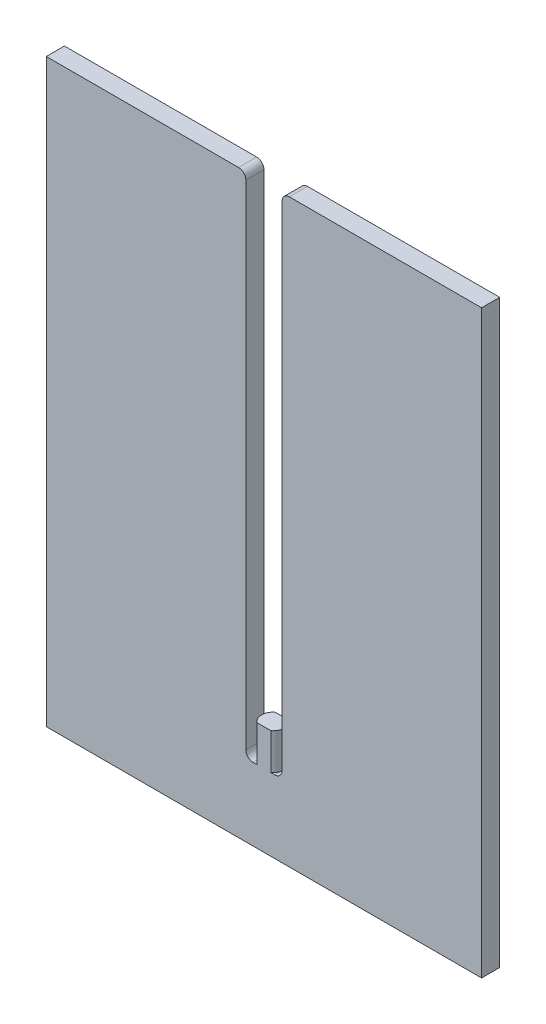
from build123d import *

# Parameters (mm, degrees)
BOSS_EXTRUDE1_DEPTH = 2.5
FILLET1_R           = 1
BOSS_EXTRUDE2_DEPTH = 5


with BuildPart() as part:
    # Sketch1 → Boss-Extrude1 (new body)
    with BuildSketch(Plane.XY):
        Polygon((-2.5, 40), (-2.5, -30), (2.5, -30), (2.5, 40), (30, 40), (30, -40), (-30, -40), (-30, 40), align=None)
    extrude(amount=BOSS_EXTRUDE1_DEPTH)

    # Fillet1
    fillet1_edges = [part.edges().sort_by_distance(p)[0] for p in [
        (-2.5, 40, 1.25),
        (-2.5, -30, 1.25),
        (2.5, -30, 1.25),
        (2.5, 40, 1.25),
    ]]
    fillet(fillet1_edges, radius=FILLET1_R)

    # Sketch2 → Boss-Extrude2 (add)
    with BuildSketch(Plane(origin=(0, -30, 0), x_dir=(1, 0, 0), z_dir=(0, 1, 0))):
        with BuildLine():
            Line((-0.957859614, 0), (0.957859614, 0))
            ThreePointArc((0.957859614, 0), (1.5748, -1.25), (0.957859614, -2.5))
            Line((0.957859614, -2.5), (-0.957859614, -2.5))
            ThreePointArc((-0.957859614, -2.5), (-1.5748, -1.25), (-0.957859614, 0))
        make_face()
    extrude(amount=BOSS_EXTRUDE2_DEPTH)


solid = part.part
